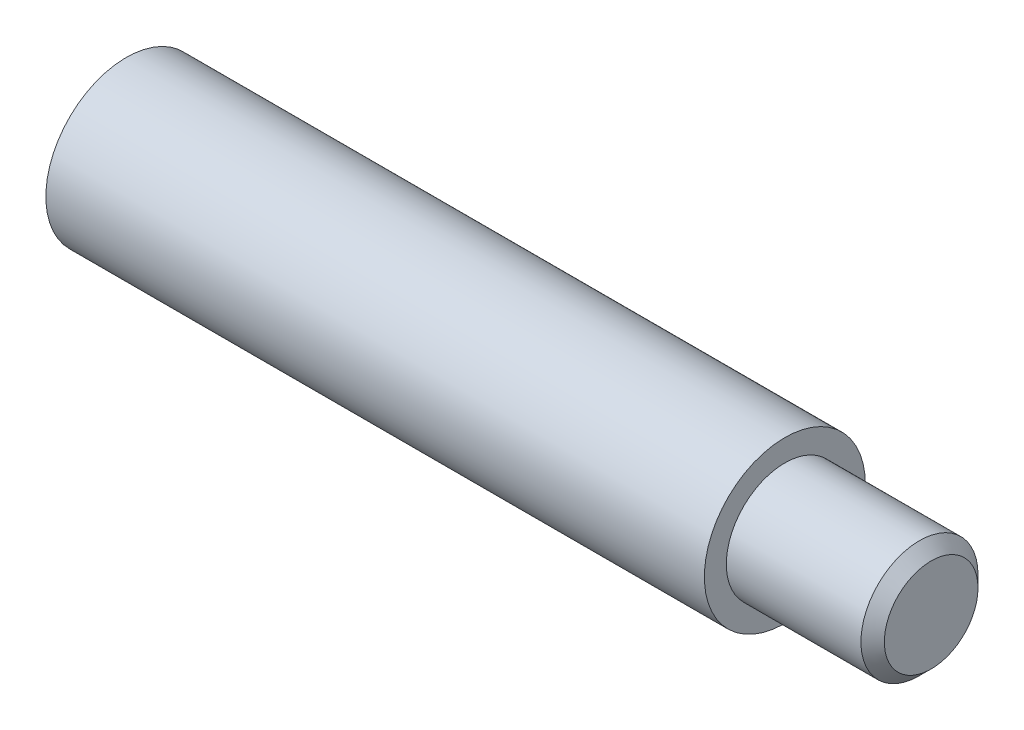
from build123d import *


with BuildPart() as part:
    # Sketch1 → Revolve1 (revolve)
    with BuildSketch(Plane.XY):
        Polygon((-15.5, 2.4585), (-14.022784168, 0), (27.5, 0), (27.5, 3.2), (26.7, 4), (17.5, 4), (17.5, 5.5), (-27.5, 5.5), (-27.5, 3.2585), (-26.7, 2.4585), align=None)
    revolve(axis=Axis((-27.5, 0, 0), (1, 0, 0)))


solid = part.part
